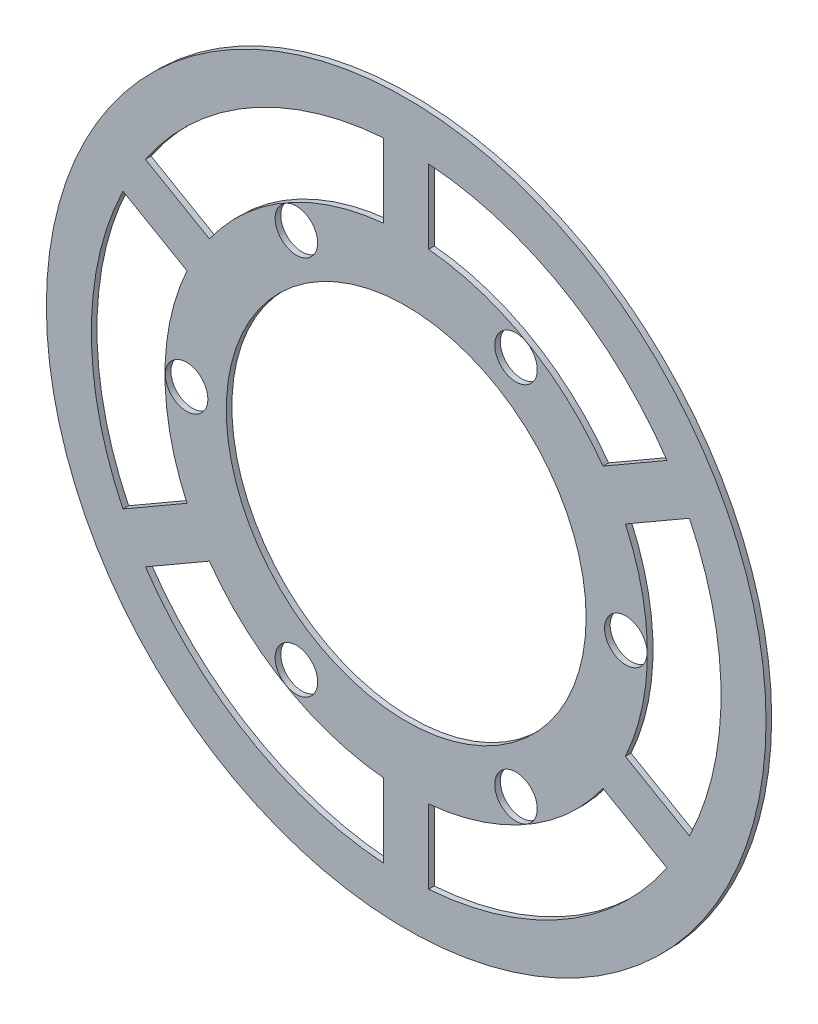
from build123d import *

# Parameters (mm, degrees)
SKETCH1_R           = 25.4
SKETCH1_R_2         = 1.5
SKETCH1_R_3         = 12.7
BOSS_EXTRUDE1_DEPTH = 0.396875


with BuildPart() as part:
    # Sketch1 → Boss-Extrude1 (new body)
    with BuildSketch(Plane.XY):
        Circle(SKETCH1_R)
        with Locations((-15.5, 0)):
            Circle(SKETCH1_R_2, mode=Mode.SUBTRACT)
        with Locations((-7.75, 13.423393759)):
            Circle(SKETCH1_R_2, mode=Mode.SUBTRACT)
        with Locations((7.75, 13.423393759)):
            Circle(SKETCH1_R_2, mode=Mode.SUBTRACT)
        with Locations((15.5, 0)):
            Circle(SKETCH1_R_2, mode=Mode.SUBTRACT)
        with Locations((7.75, -13.423393759)):
            Circle(SKETCH1_R_2, mode=Mode.SUBTRACT)
        with Locations((-7.75, -13.423393759)):
            Circle(SKETCH1_R_2, mode=Mode.SUBTRACT)
        Circle(SKETCH1_R_3, mode=Mode.SUBTRACT)
        with BuildLine():
            Line((-1.58439638, 16.926006266), (-1.58439638, 22.168453106))
            ThreePointArc((-1.58439638, 22.168453106), (-11.1125, 19.247414599), (-18.406245362, 12.456354068))
            Line((-18.406245362, 12.456354068), (-13.866153221, 9.835130648))
            ThreePointArc((-13.866153221, 9.835130648), (-13.876900865, 9.842174678), (-13.88768889, 9.849154838))
            ThreePointArc((-13.88768889, 9.849154838), (-8.512839622, 14.744670742), (-1.58577385, 16.951668798))
            ThreePointArc((-1.58577385, 16.951668798), (-1.585122867, 16.938836014), (-1.58439638, 16.926006266))
        make_face(mode=Mode.SUBTRACT)
        with BuildLine():
            Line((1.58439638, 16.926006266), (1.58439638, 22.168453106))
            ThreePointArc((1.58439638, 22.168453106), (11.1125, 19.247414599), (18.406245362, 12.456354068))
            Line((18.406245362, 12.456354068), (13.866153221, 9.835130648))
            ThreePointArc((13.866153221, 9.835130648), (13.876900865, 9.842174678), (13.88768889, 9.849154838))
            ThreePointArc((13.88768889, 9.849154838), (8.512839622, 14.744670742), (1.58577385, 16.951668798))
            ThreePointArc((1.58577385, 16.951668798), (1.585122867, 16.938836014), (1.58439638, 16.926006266))
        make_face(mode=Mode.SUBTRACT)
        with BuildLine():
            Line((15.450549601, 7.090875618), (19.990641742, 9.712099038))
            ThreePointArc((19.990641742, 9.712099038), (22.225, 0), (19.990641742, -9.712099038))
            Line((19.990641742, -9.712099038), (15.450549601, -7.090875618))
            ThreePointArc((15.450549601, -7.090875618), (15.462023732, -7.096661336), (15.47346274, -7.10251396))
            ThreePointArc((15.47346274, -7.10251396), (17.025679244, 0), (15.47346274, 7.10251396))
            ThreePointArc((15.47346274, 7.10251396), (15.462023732, 7.096661336), (15.450549601, 7.090875618))
        make_face(mode=Mode.SUBTRACT)
        with BuildLine():
            Line((-15.450549601, 7.090875618), (-19.990641742, 9.712099038))
            ThreePointArc((-19.990641742, 9.712099038), (-22.225, 0), (-19.990641742, -9.712099038))
            Line((-19.990641742, -9.712099038), (-15.450549601, -7.090875618))
            ThreePointArc((-15.450549601, -7.090875618), (-15.462023732, -7.096661336), (-15.47346274, -7.10251396))
            ThreePointArc((-15.47346274, -7.10251396), (-17.025679244, 0), (-15.47346274, 7.10251396))
            ThreePointArc((-15.47346274, 7.10251396), (-15.462023732, 7.096661336), (-15.450549601, 7.090875618))
        make_face(mode=Mode.SUBTRACT)
        with BuildLine():
            Line((-13.866153221, -9.835130648), (-18.406245362, -12.456354068))
            ThreePointArc((-18.406245362, -12.456354068), (-11.1125, -19.247414599), (-1.58439638, -22.168453106))
            Line((-1.58439638, -22.168453106), (-1.58439638, -16.926006266))
            ThreePointArc((-1.58439638, -16.926006266), (-1.585122867, -16.938836014), (-1.58577385, -16.951668798))
            ThreePointArc((-1.58577385, -16.951668798), (-8.512839622, -14.744670742), (-13.88768889, -9.849154838))
            ThreePointArc((-13.88768889, -9.849154838), (-13.876900865, -9.842174678), (-13.866153221, -9.835130648))
        make_face(mode=Mode.SUBTRACT)
        with BuildLine():
            Line((1.58439638, -16.926006266), (1.58439638, -22.168453106))
            ThreePointArc((1.58439638, -22.168453106), (11.1125, -19.247414599), (18.406245362, -12.456354068))
            Line((18.406245362, -12.456354068), (13.866153221, -9.835130648))
            ThreePointArc((13.866153221, -9.835130648), (13.876900865, -9.842174678), (13.88768889, -9.849154838))
            ThreePointArc((13.88768889, -9.849154838), (8.512839622, -14.744670742), (1.58577385, -16.951668798))
            ThreePointArc((1.58577385, -16.951668798), (1.585122867, -16.938836014), (1.58439638, -16.926006266))
        make_face(mode=Mode.SUBTRACT)
    extrude(amount=BOSS_EXTRUDE1_DEPTH)


solid = part.part
